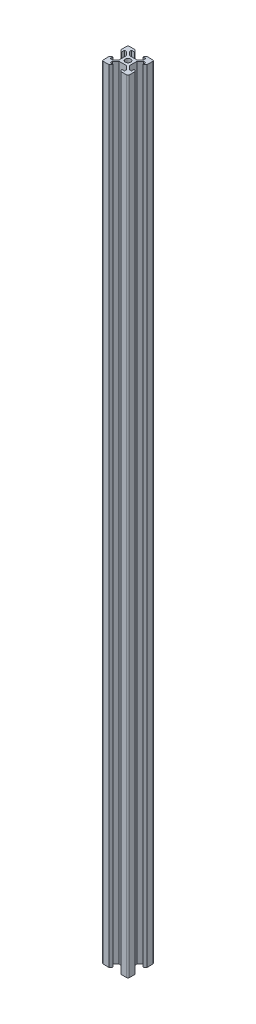
from build123d import *

# Parameters (mm, degrees)
SKETCH1_R           = 2.1
BOSS_EXTRUDE1_DEPTH = 600


with BuildPart() as part:
    # Sketch1 → Boss-Extrude1 (new body)
    with BuildSketch(Plane(origin=(0, 0, 0), x_dir=(1, 0, 0), z_dir=(0, 1, 0))):
        with BuildLine():
            Line((-5.5, 8.2), (-3.125, 8.2))
            Line((-3.125, 8.2), (-4.58, 10))
            Line((-4.58, 10), (-9, 10))
            ThreePointArc((-9, 10), (-9.707106781, 9.707106781), (-10, 9))
            Line((-10, 9), (-10, 4.58))
            Line((-10, 4.58), (-8.2, 3.125))
            Line((-8.2, 3.125), (-8.2, 5.5))
            Line((-8.2, 5.5), (-6.56, 5.5))
            Line((-6.56, 5.5), (-3.9, 2.84))
            Line((-3.9, 2.84), (-3.9, -2.84))
            Line((-3.9, -2.84), (-6.56, -5.5))
            Line((-6.56, -5.5), (-8.2, -5.5))
            Line((-8.2, -5.5), (-8.2, -3.125))
            Line((-8.2, -3.125), (-10, -4.58))
            Line((-10, -4.58), (-10, -9))
            ThreePointArc((-10, -9), (-9.707106781, -9.707106781), (-9, -10))
            Line((-9, -10), (-4.58, -10))
            Line((-4.58, -10), (-3.125, -8.2))
            Line((-3.125, -8.2), (-5.5, -8.2))
            Line((-5.5, -8.2), (-5.5, -6.56))
            Line((-5.5, -6.56), (-2.84, -3.9))
            Line((-2.84, -3.9), (2.84, -3.9))
            Line((2.84, -3.9), (5.5, -6.56))
            Line((5.5, -6.56), (5.5, -8.2))
            Line((5.5, -8.2), (3.125, -8.2))
            Line((3.125, -8.2), (4.58, -10))
            Line((4.58, -10), (9, -10))
            ThreePointArc((9, -10), (9.707106781, -9.707106781), (10, -9))
            Line((10, -9), (10, -4.58))
            Line((10, -4.58), (8.2, -3.125))
            Line((8.2, -3.125), (8.2, -5.5))
            Line((8.2, -5.5), (6.56, -5.5))
            Line((6.56, -5.5), (3.9, -2.84))
            Line((3.9, -2.84), (3.9, 2.84))
            Line((3.9, 2.84), (6.56, 5.5))
            Line((6.56, 5.5), (8.2, 5.5))
            Line((8.2, 5.5), (8.2, 3.125))
            Line((8.2, 3.125), (10, 4.58))
            Line((10, 4.58), (10, 9))
            ThreePointArc((10, 9), (9.707106781, 9.707106781), (9, 10))
            Line((9, 10), (4.58, 10))
            Line((4.58, 10), (3.125, 8.2))
            Line((3.125, 8.2), (5.5, 8.2))
            Line((5.5, 8.2), (5.5, 6.56))
            Line((5.5, 6.56), (2.84, 3.9))
            Line((2.84, 3.9), (-2.84, 3.9))
            Line((-2.84, 3.9), (-5.5, 6.56))
            Line((-5.5, 6.56), (-5.5, 8.2))
        make_face()
        Circle(SKETCH1_R, mode=Mode.SUBTRACT)
    extrude(amount=BOSS_EXTRUDE1_DEPTH)


solid = part.part
